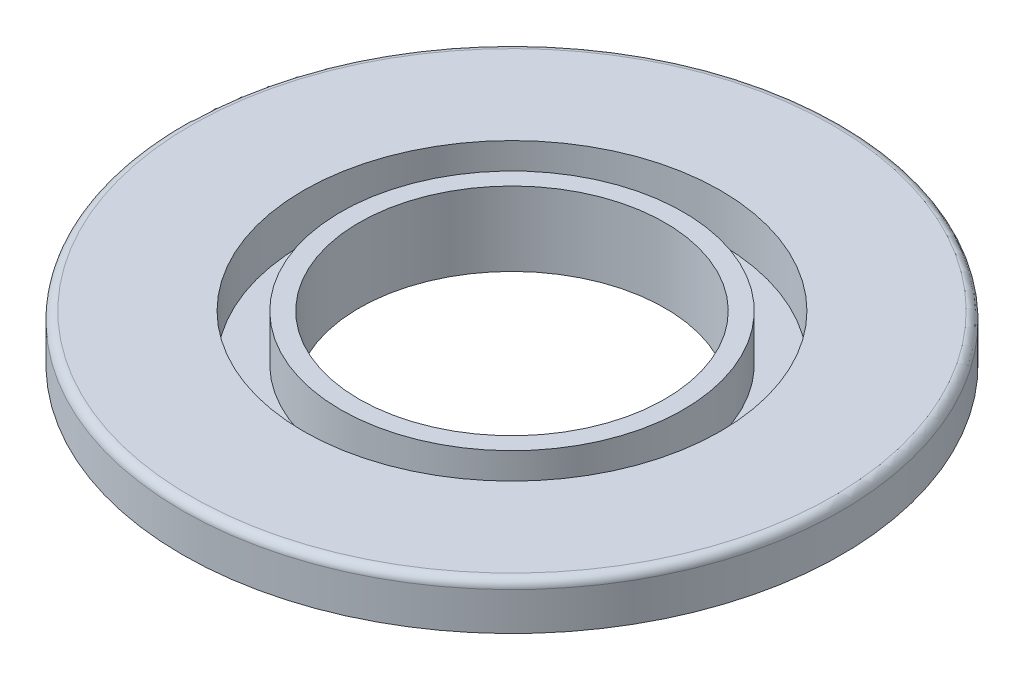
from build123d import *

# Parameters (mm, degrees)
FILLET3_R = 1.7
FILLET4_R = 1.7


with BuildPart() as part:
    # Sketch1 → Revolve2 (revolve)
    with BuildSketch(Plane.XY):
        Polygon((-71.835738672, 25.657855278), (-71.835738672, 31.241430002), (-90.666618133, 31.241430002), (-90.666618133, 40.656869732), (-66.142682091, 40.656869732), (-66.142682091, 31.241430002), (-58.588433936, 31.241430002), (-58.588433936, 40.656869732), (-54.866050787, 40.656869732), (-54.866050787, 25.657855278), (-66.142682091, 25.657855278), (-66.142682091, 19.964798697), (-69.974547098, 19.964798697), (-69.974547098, 25.657855278), align=None)
    revolve(axis=Axis((-23.866050787, 40.656869732, 0), (0, -1, 0)))

    # Fillet3
    fillet3_edges = [part.edges().sort_by_distance(p)[0] for p in [
        (42.93451656, 40.656869732, 0),
    ]]
    fillet(fillet3_edges, radius=FILLET3_R)

    # Fillet4
    fillet4_edges = [part.edges().sort_by_distance(p)[0] for p in [
        (18.410580518, 25.657855278, 0),
    ]]
    fillet(fillet4_edges, radius=FILLET4_R)


solid = part.part
